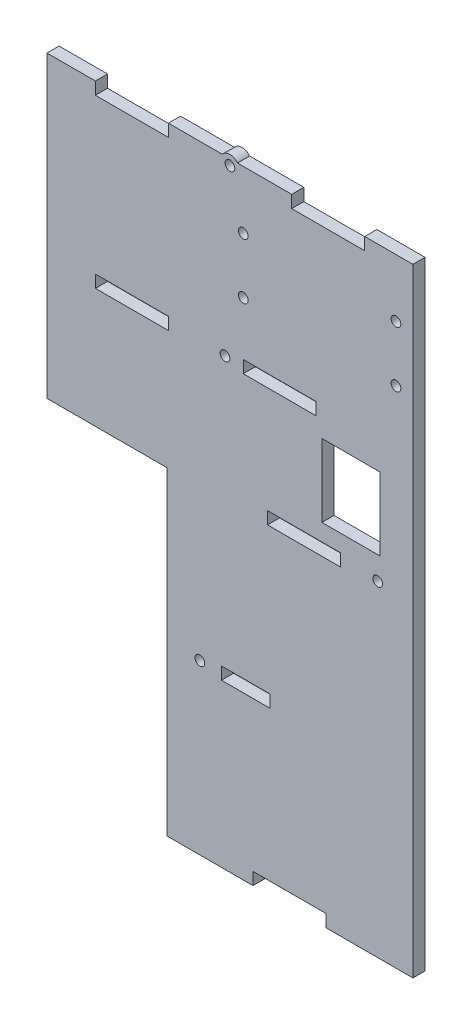
from build123d import *

# Parameters (mm, degrees)
SKETCH1_W           = 151
SKETCH1_H           = 255
BOSS_EXTRUDE1_DEPTH = 5
SKETCH2_W           = 49.486524855
SKETCH2_H           = 131.582895272
CUT_EXTRUDE1_DEPTH  = 5
SKETCH3_W           = 30.1
SKETCH3_H           = 5.1
SKETCH3_W_2         = 20.1
CUT_EXTRUDE2_DEPTH  = 5
SKETCH4_R           = 2
CUT_EXTRUDE3_DEPTH  = 5
SKETCH5_R           = 4
SKETCH5_R_2         = 2
BOSS_EXTRUDE2_DEPTH = 5
SKETCH6_W           = 24
SKETCH6_H           = 30
CUT_EXTRUDE4_DEPTH  = 5
SKETCH7_R           = 2
CUT_EXTRUDE5_DEPTH  = 10


with BuildPart() as part:
    # Sketch1 → Boss-Extrude1 (new body)
    with BuildSketch(Plane.XY):
        Rectangle(SKETCH1_W, SKETCH1_H)
    extrude(amount=BOSS_EXTRUDE1_DEPTH)

    # Sketch2 → Cut-Extrude1 (cut)
    with BuildSketch(Plane.XY.offset(5)):
        with Locations((-50.756737573, -61.708552364)):
            Rectangle(SKETCH2_W, SKETCH2_H)
    extrude(amount=-CUT_EXTRUDE1_DEPTH, mode=Mode.SUBTRACT)

    # Sketch3 → Cut-Extrude2 (cut)
    with BuildSketch(Plane.XY.offset(5)):
        with Locations((-40.45, 124.95)):
            Rectangle(SKETCH3_W, SKETCH3_H)
        with Locations((40.55, 124.95)):
            Rectangle(SKETCH3_W, SKETCH3_H)
        with Locations((-40.440248728, 55.95)):
            Rectangle(SKETCH3_W, SKETCH3_H)
        with Locations((20.55, 55.95)):
            Rectangle(SKETCH3_W, SKETCH3_H)
        with Locations((30.55, 6.95)):
            Rectangle(SKETCH3_W, SKETCH3_H)
        with Locations((6.55, -58.05)):
            Rectangle(SKETCH3_W_2, SKETCH3_H)
        with Locations((24.55, -124.95)):
            Rectangle(SKETCH3_W, SKETCH3_H)
    extrude(amount=-CUT_EXTRUDE2_DEPTH, mode=Mode.SUBTRACT)

    # Sketch4 → Cut-Extrude3 (cut)
    with BuildSketch(Plane.XY.offset(5)):
        with Locations((0, 125)):
            Circle(SKETCH4_R)
        with Locations((-2.045010771, 56)):
            Circle(SKETCH4_R)
        with Locations((60.936739195, 7)):
            Circle(SKETCH4_R)
        with Locations((-12.405611853, -58)):
            Circle(SKETCH4_R)
    extrude(amount=-CUT_EXTRUDE3_DEPTH, mode=Mode.SUBTRACT)

    # Sketch5 → Boss-Extrude2 (add)
    with BuildSketch(Plane.XY.offset(5)):
        with Locations((0, 125)):
            Circle(SKETCH5_R)
        with Locations((0, 125)):
            Circle(SKETCH5_R_2, mode=Mode.SUBTRACT)
    extrude(amount=-BOSS_EXTRUDE2_DEPTH)

    # Sketch6 → Cut-Extrude4 (cut)
    with BuildSketch(Plane.XY.offset(5)):
        with Locations((49.941975166, 31.5)):
            Rectangle(SKETCH6_W, SKETCH6_H)
    extrude(amount=-CUT_EXTRUDE4_DEPTH, mode=Mode.SUBTRACT)

    # Sketch7 → Cut-Extrude5 (cut)
    with BuildSketch(Plane.XY.offset(5)):
        with Locations((68.5, 103.580315126)):
            Circle(SKETCH7_R)
        with Locations((5.5, 80.580315126)):
            Circle(SKETCH7_R)
        with Locations((5.5, 103.580315126)):
            Circle(SKETCH7_R)
        with Locations((68.5, 80.580315126)):
            Circle(SKETCH7_R)
    extrude(amount=-CUT_EXTRUDE5_DEPTH, mode=Mode.SUBTRACT)


solid = part.part
